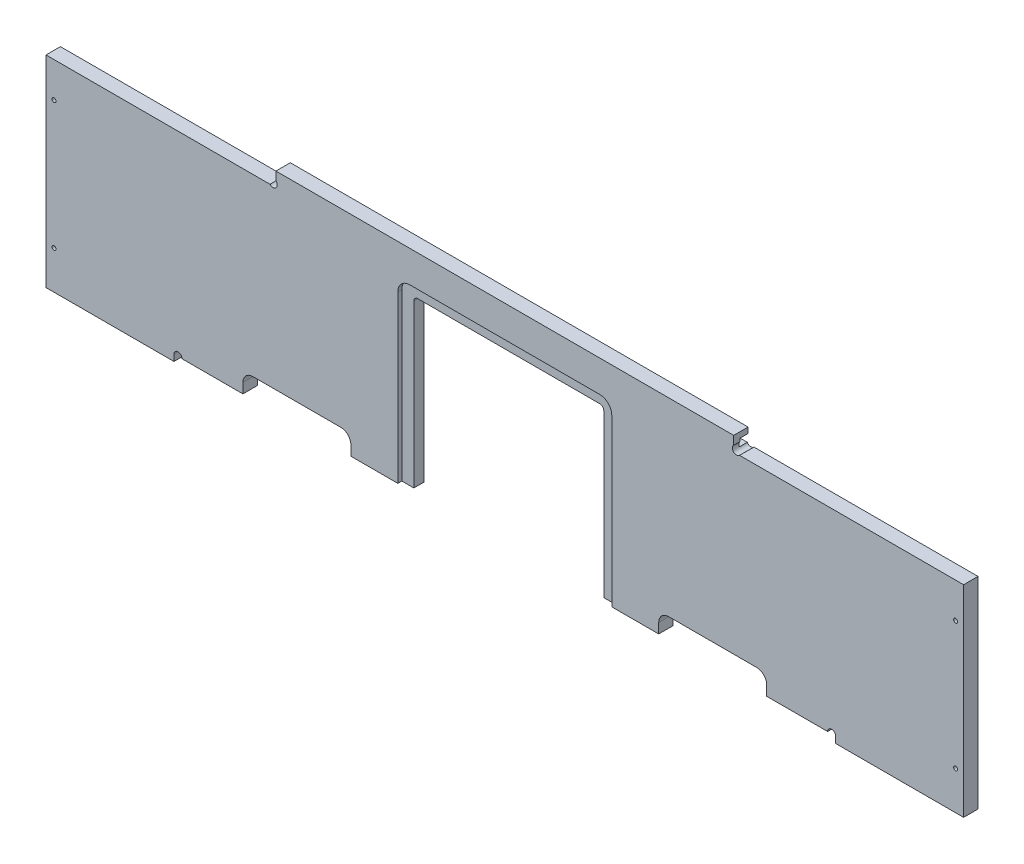
from build123d import *

# Parameters (mm, degrees)
THICKNESS_MAINOUTLINE_DEPTH = 11.43
CORNERPOCKETRADIUS_R        = 3.302
CUT_EXTRUDE4_DEPTH          = 11.43
FLANGEDEPTH_DEPTH           = 3.175
SCREWHOLES_R                = 1.5875
CUT_EXTRUDE2_DEPTH          = 11.43
PLEXCHANNEL_W               = 363.5375
PLEXCHANNEL_H               = 6.35
PLEXCHANNEL_DEPTH_DEPTH     = 6.35
SKETCH7_W                   = 101.6
SKETCH7_H                   = 5.08
EXTRUDE2_DEPTH              = 11.43
SKETCH8_R                   = 3.175
CUT_EXTRUDE5_DEPTH          = 11.43


with BuildPart() as part:
    # MainOutline → Thickness_MainOutline (new body)
    with BuildSketch(Plane.XY):
        with BuildLine():
            Line((-5740.4, 1539.24), (-5740.4, 1384.3))
            Line((-5740.4, 1384.3), (-5584.03125, 1384.3))
            Line((-5584.03125, 1384.3), (-5584.03125, 1392.2375))
            ThreePointArc((-5584.03125, 1392.2375), (-5581.706410076, 1397.850160076), (-5576.09375, 1400.175))
            Line((-5576.09375, 1400.175), (-5506.24375, 1400.175))
            ThreePointArc((-5506.24375, 1400.175), (-5500.631089924, 1397.850160076), (-5498.30625, 1392.2375))
            Line((-5498.30625, 1392.2375), (-5498.30625, 1384.3))
            Line((-5498.30625, 1384.3), (-5451.475, 1384.3))
            Line((-5451.475, 1384.3), (-5451.475, 1512.8875))
            ThreePointArc((-5451.475, 1512.8875), (-5450.54506403, 1515.13256403), (-5448.3, 1516.0625))
            Line((-5448.3, 1516.0625), (-5303.8375, 1516.0625))
            ThreePointArc((-5303.8375, 1516.0625), (-5301.59243597, 1515.13256403), (-5300.6625, 1512.8875))
            Line((-5300.6625, 1512.8875), (-5300.6625, 1384.3))
            Line((-5300.6625, 1384.3), (-5253.83125, 1384.3))
            Line((-5253.83125, 1384.3), (-5253.83125, 1392.2375))
            ThreePointArc((-5253.83125, 1392.2375), (-5251.506410076, 1397.850160076), (-5245.89375, 1400.175))
            Line((-5245.89375, 1400.175), (-5176.04375, 1400.175))
            ThreePointArc((-5176.04375, 1400.175), (-5170.431089924, 1397.850160076), (-5168.10625, 1392.2375))
            Line((-5168.10625, 1392.2375), (-5168.10625, 1384.3))
            Line((-5168.10625, 1384.3), (-5011.7375, 1384.3))
            Line((-5011.7375, 1384.3), (-5011.7375, 1539.24))
            Line((-5011.7375, 1539.24), (-5194.3, 1539.24))
            Line((-5194.3, 1539.24), (-5194.3, 1550.67))
            Line((-5194.3, 1550.67), (-5557.8375, 1550.67))
            Line((-5557.8375, 1550.67), (-5557.8375, 1539.24))
            Line((-5557.8375, 1539.24), (-5740.4, 1539.24))
        make_face()
    extrude(amount=-THICKNESS_MAINOUTLINE_DEPTH)

    # CornerPocketRadius → Cut-Extrude4 (cut)
    with BuildSketch(Plane.XY):
        with Locations((-5560.08256403, 1541.48506403)):
            Circle(CORNERPOCKETRADIUS_R)
        with Locations((-5192.05493597, 1541.48506403)):
            Circle(CORNERPOCKETRADIUS_R)
    extrude(amount=-CUT_EXTRUDE4_DEPTH, mode=Mode.SUBTRACT)

    # PowerBoxFlange → FlangeDepth (cut)
    with BuildSketch(Plane.XY):
        with BuildLine():
            Line((-5297.4875, 1377.95), (-5454.65, 1377.95))
            ThreePointArc((-5454.65, 1377.95), (-5459.140128061, 1379.809871939), (-5461, 1384.3))
            Line((-5461, 1384.3), (-5461, 1516.0625))
            ThreePointArc((-5461, 1516.0625), (-5458.210192091, 1522.797692091), (-5451.475, 1525.5875))
            Line((-5451.475, 1525.5875), (-5300.6625, 1525.5875))
            ThreePointArc((-5300.6625, 1525.5875), (-5293.927307909, 1522.797692091), (-5291.1375, 1516.0625))
            Line((-5291.1375, 1516.0625), (-5291.1375, 1384.3))
            ThreePointArc((-5291.1375, 1384.3), (-5292.997371939, 1379.809871939), (-5297.4875, 1377.95))
        make_face()
    extrude(amount=-FLANGEDEPTH_DEPTH, mode=Mode.SUBTRACT)

    # ScrewHoles → Cut-Extrude2 (cut)
    with BuildSketch(Plane.XY):
        with Locations((-5734.05, 1511.3)):
            Circle(SCREWHOLES_R)
        with Locations((-5734.05, 1409.7)):
            Circle(SCREWHOLES_R)
        with Locations((-5018.0875, 1409.7)):
            Circle(SCREWHOLES_R)
        with Locations((-5018.0875, 1511.3)):
            Circle(SCREWHOLES_R)
    extrude(amount=-CUT_EXTRUDE2_DEPTH, mode=Mode.SUBTRACT)

    # PlexChannel → PlexChannel_Depth (cut)
    with BuildSketch(Plane(origin=(0, 0, -11.43), x_dir=(-1, 0, 0), z_dir=(0, 0, -1))):
        with Locations((5376.06875, 1543.05)):
            Rectangle(PLEXCHANNEL_W, PLEXCHANNEL_H)
    extrude(amount=-PLEXCHANNEL_DEPTH_DEPTH, mode=Mode.SUBTRACT)

    # Sketch7 → Extrude2 (add)
    with BuildSketch(Plane.XY):
        with Locations((-5689.6, 1381.76)):
            Rectangle(SKETCH7_W, SKETCH7_H)
        with Locations((-5062.5375, 1381.76)):
            Rectangle(SKETCH7_W, SKETCH7_H)
    extrude(amount=-EXTRUDE2_DEPTH)

    # Sketch8 → Cut-Extrude5 (cut)
    with BuildSketch(Plane.XY):
        with Locations((-5635.625, 1384.3)):
            Circle(SKETCH8_R)
        with Locations((-5116.5125, 1384.3)):
            Circle(SKETCH8_R)
    extrude(amount=-CUT_EXTRUDE5_DEPTH, mode=Mode.SUBTRACT)


solid = part.part
